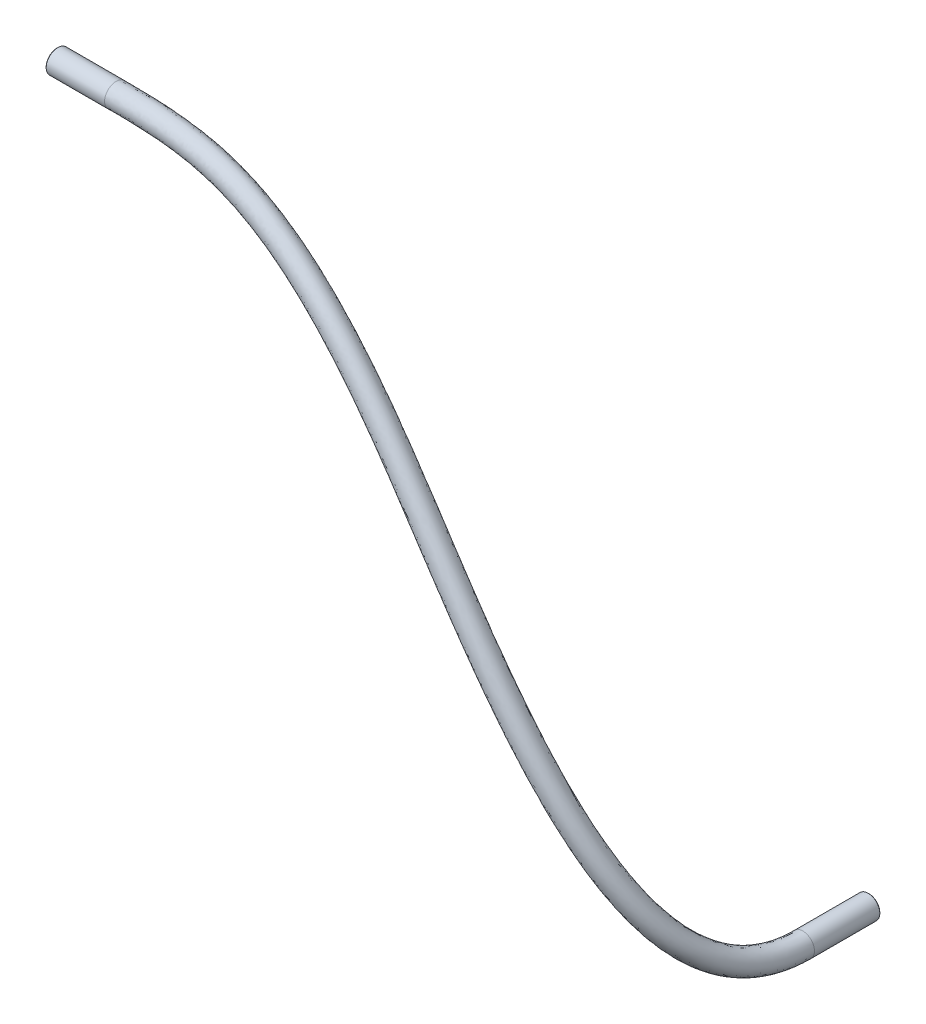
from build123d import *

# Parameters (mm, degrees)
SKETCH1_R     = 2
SKETCH1_R_2   = 1.3
CHAMFER1_SIZE = 0.127


with BuildPart() as part:
    # Sweep1: sweep along a curve in space
    with BuildLine() as sweep1_path:
        Line((201.31049714, -198.353558716, -49.6875), (201.31049714, -198.353558716, -61.0875))
        add(Edge.make_bspline(
            [(107.025, -106.482256564, -25.525), (123.309886494, -106.482256564, -25.525), (146.459795635, -109.965710479, -26.204843783), (201.31049714, -198.353558716, -18.695098755), (201.31049714, -198.353558716, -49.6875)],
            knots=[0, 0, 0, 0, 0.513705976, 1, 1, 1, 1], degree=3))
        Line((96.825, -106.482256564, -25.525), (107.025, -106.482256564, -25.525))
    # Sketch1 → Sweep1 (sweep)
    with BuildSketch(Plane(origin=(104.925, 0, 0), x_dir=(0, 0, -1), z_dir=(1, 0, 0))):
        with Locations((25.525, -106.482256564)):
            Circle(SKETCH1_R)
        with Locations((25.525, -106.482256564)):
            Circle(SKETCH1_R_2, mode=Mode.SUBTRACT)
    sweep(path=sweep1_path.line, is_frenet=True)

    # Chamfer1
    chamfer1_edges = [part.edges().sort_by_distance(p)[0] for p in [
        (96.825, -106.482256564, -24.225),
        (200.357661376, -199.23792516, -61.0875),
        (96.825, -106.482256564, -23.525),
        (199.844595964, -199.714122476, -61.0875),
    ]]
    chamfer(chamfer1_edges, length=CHAMFER1_SIZE)


solid = part.part
